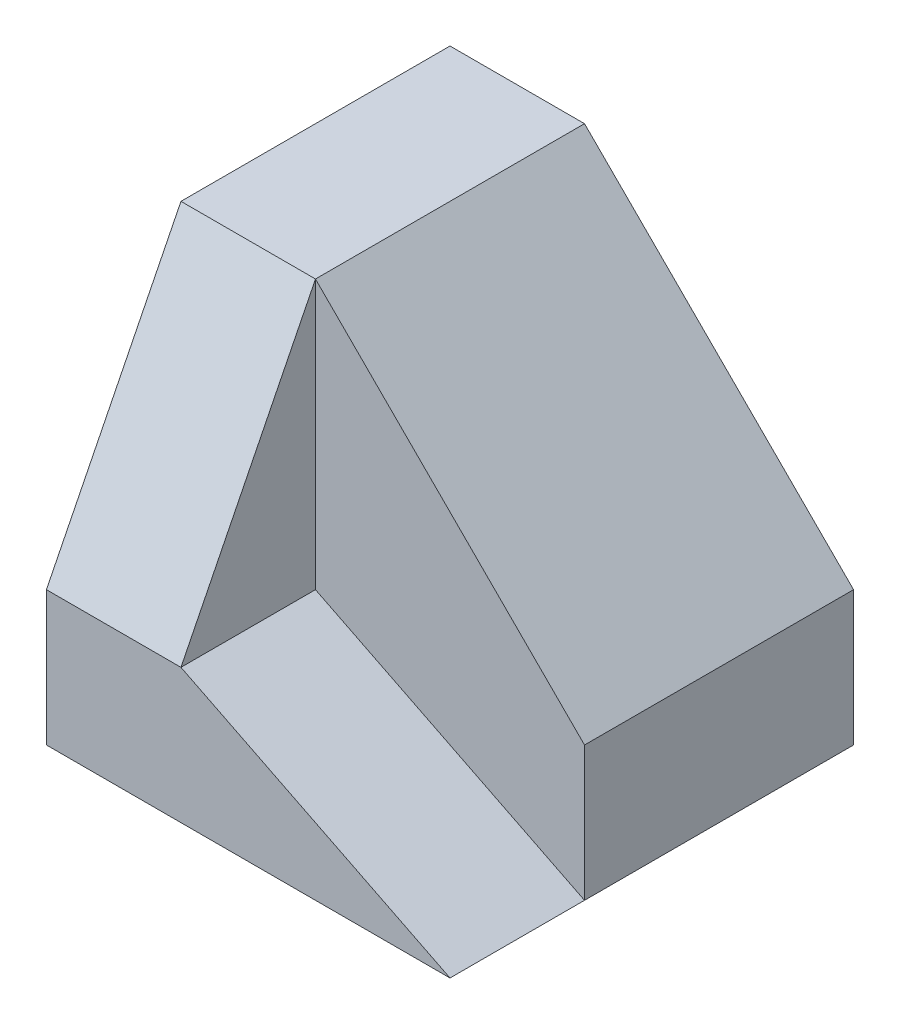
from build123d import *

# Parameters (mm, degrees)
SALIENTE_EXTRUIR1_DEPTH = 60
CORTAR_EXTRUIR1_DEPTH   = 20
CORTAR_EXTRUIR2_REACH   = 22


with BuildPart() as part:
    # Croquis1 → Saliente-Extruir1 (new body)
    with BuildSketch(Plane.XY):
        Polygon((0, 0), (60, 0), (60, 20), (20, 60), (0, 60), align=None)
    extrude(amount=-SALIENTE_EXTRUIR1_DEPTH)

    # Croquis2 → Cortar-Extruir1 (cut)
    with BuildSketch(Plane.XY):
        Polygon((20, 60), (20, 20), (60, 0), (60, 20), align=None)
    extrude(amount=-CORTAR_EXTRUIR1_DEPTH, mode=Mode.SUBTRACT)

    # Croquis3 → Cortar-Extruir2 (cut, up to next)
    with BuildSketch(Plane(origin=(20, 0, 0), x_dir=(0, 0, -1), z_dir=(1, 0, 0)), mode=Mode.PRIVATE) as cortar_extruir2_sk1:
        Polygon((0, 20), (20, 60), (0, 60), align=None)
    cortar_extruir2_tool1 = extrude(cortar_extruir2_sk1.sketch, amount=-CORTAR_EXTRUIR2_REACH, mode=Mode.PRIVATE) & part.part
    add(cortar_extruir2_tool1.solids().sort_by_distance((20, 46.666667, -6.666667))[0], mode=Mode.SUBTRACT)


solid = part.part
